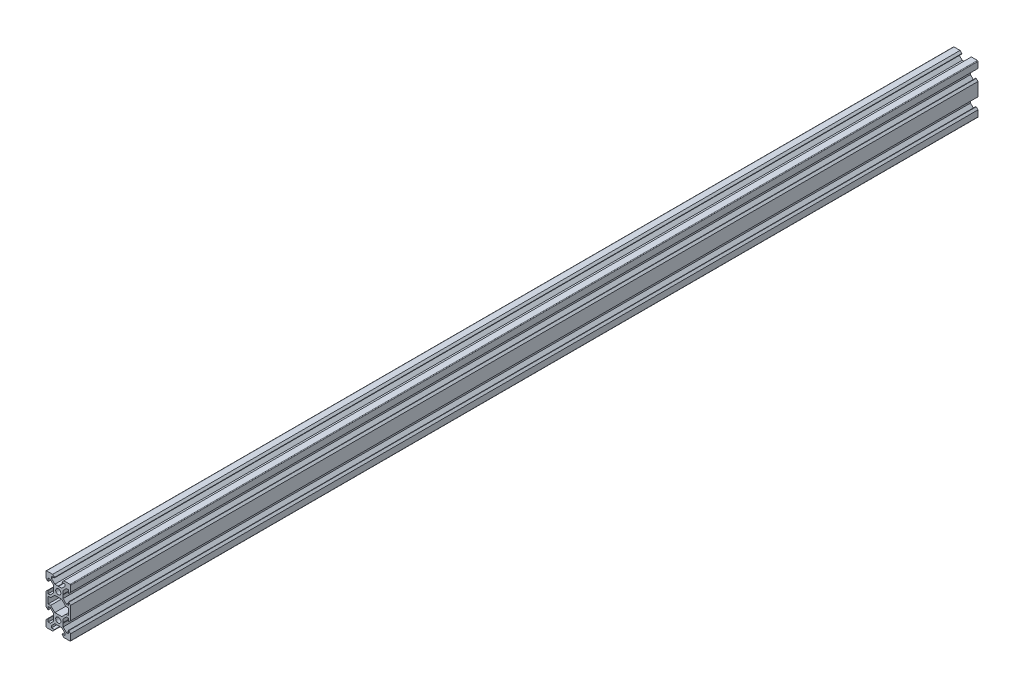
from build123d import *

# Parameters (mm, degrees)
SKETCH1_R           = 2.1
BOSS_EXTRUDE1_DEPTH = 738


with BuildPart() as part:
    # Sketch1 → Boss-Extrude1 (new body)
    with BuildSketch(Plane.XY):
        with BuildLine():
            Line((4.58, -20), (9.5, -20))
            ThreePointArc((9.5, -20), (9.853553391, -19.853553391), (10, -19.5))
            Line((10, -19.5), (10, -14.58))
            Line((10, -14.58), (8.545, -13.125))
            Line((8.545, -13.125), (8.2, -13.125))
            Line((8.2, -13.125), (8.2, -15.5))
            Line((8.2, -15.5), (6.560660172, -15.5))
            Line((6.560660172, -15.5), (3.9, -12.839339828))
            Line((3.9, -12.839339828), (3.9, -10.21))
            Line((3.9, -10.21), (3.69, -10))
            Line((3.69, -10), (3.9, -9.79))
            Line((3.9, -9.79), (3.9, -7.160660172))
            Line((3.9, -7.160660172), (6.560660172, -4.5))
            Line((6.560660172, -4.5), (8.2, -4.5))
            Line((8.2, -4.5), (8.2, -6.875))
            Line((8.2, -6.875), (8.545, -6.875))
            Line((8.545, -6.875), (10, -5.42))
            Line((10, -5.42), (10, 5.42))
            Line((10, 5.42), (8.545, 6.875))
            Line((8.545, 6.875), (8.2, 6.875))
            Line((8.2, 6.875), (8.2, 4.5))
            Line((8.2, 4.5), (6.560660172, 4.5))
            Line((6.560660172, 4.5), (3.9, 7.160660172))
            Line((3.9, 7.160660172), (3.9, 9.79))
            Line((3.9, 9.79), (3.69, 10))
            Line((3.69, 10), (3.9, 10.21))
            Line((3.9, 10.21), (3.9, 12.839339828))
            Line((3.9, 12.839339828), (6.560660172, 15.5))
            Line((6.560660172, 15.5), (8.2, 15.5))
            Line((8.2, 15.5), (8.2, 13.125))
            Line((8.2, 13.125), (8.545, 13.125))
            Line((8.545, 13.125), (10, 14.58))
            Line((10, 14.58), (10, 19.5))
            ThreePointArc((10, 19.5), (9.853553391, 19.853553391), (9.5, 20))
            Line((9.5, 20), (4.58, 20))
            Line((4.58, 20), (3.125, 18.545))
            Line((3.125, 18.545), (3.125, 18.2))
            Line((3.125, 18.2), (5.5, 18.2))
            Line((5.5, 18.2), (5.5, 16.560660172))
            Line((5.5, 16.560660172), (2.839339828, 13.9))
            Line((2.839339828, 13.9), (0.21, 13.9))
            Line((0.21, 13.9), (0, 13.69))
            Line((0, 13.69), (-0.21, 13.9))
            Line((-0.21, 13.9), (-2.839339828, 13.9))
            Line((-2.839339828, 13.9), (-5.5, 16.560660172))
            Line((-5.5, 16.560660172), (-5.5, 18.2))
            Line((-5.5, 18.2), (-3.125, 18.2))
            Line((-3.125, 18.2), (-3.125, 18.545))
            Line((-3.125, 18.545), (-4.58, 20))
            Line((-4.58, 20), (-9.5, 20))
            ThreePointArc((-9.5, 20), (-9.853553391, 19.853553391), (-10, 19.5))
            Line((-10, 19.5), (-10, 14.58))
            Line((-10, 14.58), (-8.545, 13.125))
            Line((-8.545, 13.125), (-8.2, 13.125))
            Line((-8.2, 13.125), (-8.2, 15.5))
            Line((-8.2, 15.5), (-6.560660172, 15.5))
            Line((-6.560660172, 15.5), (-3.9, 12.839339828))
            Line((-3.9, 12.839339828), (-3.9, 10.21))
            Line((-3.9, 10.21), (-3.69, 10))
            Line((-3.69, 10), (-3.9, 9.79))
            Line((-3.9, 9.79), (-3.9, 7.160660172))
            Line((-3.9, 7.160660172), (-6.560660172, 4.5))
            Line((-6.560660172, 4.5), (-8.2, 4.5))
            Line((-8.2, 4.5), (-8.2, 6.875))
            Line((-8.2, 6.875), (-8.545, 6.875))
            Line((-8.545, 6.875), (-10, 5.42))
            Line((-10, 5.42), (-10, -5.42))
            Line((-10, -5.42), (-8.545, -6.875))
            Line((-8.545, -6.875), (-8.2, -6.875))
            Line((-8.2, -6.875), (-8.2, -4.5))
            Line((-8.2, -4.5), (-6.560660172, -4.5))
            Line((-6.560660172, -4.5), (-3.9, -7.160660172))
            Line((-3.9, -7.160660172), (-3.9, -9.79))
            Line((-3.9, -9.79), (-3.69, -10))
            Line((-3.69, -10), (-3.9, -10.21))
            Line((-3.9, -10.21), (-3.9, -12.839339828))
            Line((-3.9, -12.839339828), (-6.560660172, -15.5))
            Line((-6.560660172, -15.5), (-8.2, -15.5))
            Line((-8.2, -15.5), (-8.2, -13.125))
            Line((-8.2, -13.125), (-8.545, -13.125))
            Line((-8.545, -13.125), (-10, -14.58))
            Line((-10, -14.58), (-10, -19.5))
            ThreePointArc((-10, -19.5), (-9.853553391, -19.853553391), (-9.5, -20))
            Line((-9.5, -20), (-4.58, -20))
            Line((-4.58, -20), (-3.125, -18.545))
            Line((-3.125, -18.545), (-3.125, -18.2))
            Line((-3.125, -18.2), (-5.5, -18.2))
            Line((-5.5, -18.2), (-5.5, -16.560660172))
            Line((-5.5, -16.560660172), (-2.839339828, -13.9))
            Line((-2.839339828, -13.9), (-0.21, -13.9))
            Line((-0.21, -13.9), (0, -13.69))
            Line((0, -13.69), (0.21, -13.9))
            Line((0.21, -13.9), (2.839339828, -13.9))
            Line((2.839339828, -13.9), (5.5, -16.560660172))
            Line((5.5, -16.560660172), (5.5, -18.2))
            Line((5.5, -18.2), (3.125, -18.2))
            Line((3.125, -18.2), (3.125, -18.545))
            Line((3.125, -18.545), (4.58, -20))
        make_face()
        with Locations((0, -10)):
            Circle(SKETCH1_R, mode=Mode.SUBTRACT)
        Polygon((-6.239339828, -2.7), (-8.2, -2.7), (-8.2, 2.7), (-6.239339828, 2.7), (-2.839339828, 6.1), (2.839339828, 6.1), (6.239339828, 2.7), (8.2, 2.7), (8.2, -2.7), (6.239339828, -2.7), (2.839339828, -6.1), (-2.839339828, -6.1), align=None, mode=Mode.SUBTRACT)
        with Locations((0, 10)):
            Circle(SKETCH1_R, mode=Mode.SUBTRACT)
    extrude(amount=BOSS_EXTRUDE1_DEPTH)


solid = part.part
